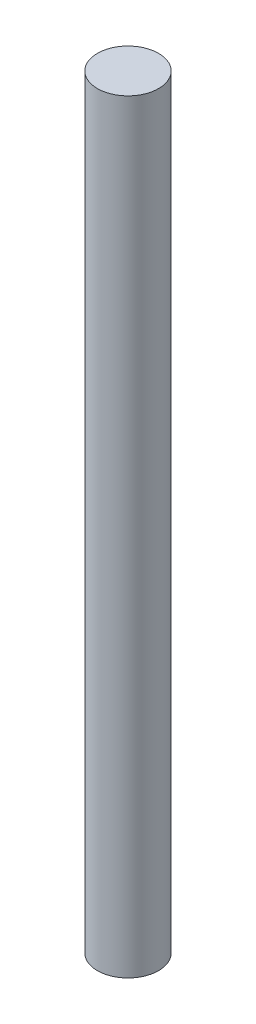
from build123d import *

# Parameters (mm, degrees)
SKETCH2_R           = 4
BOSS_EXTRUDE1_DEPTH = 100


with BuildPart() as part:
    # Sketch2 → Boss-Extrude1 (new body)
    with BuildSketch(Plane(origin=(0, 0, 0), x_dir=(1, 0, 0), z_dir=(0, 1, 0))):
        Circle(SKETCH2_R)
    extrude(amount=BOSS_EXTRUDE1_DEPTH)


solid = part.part
